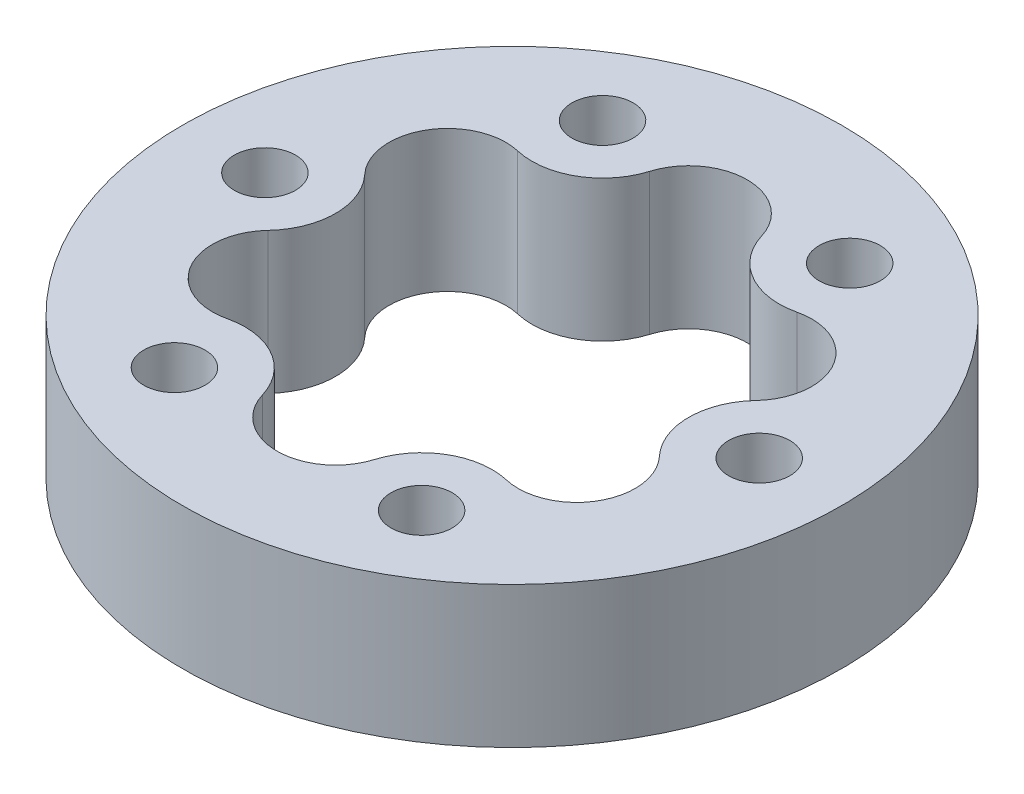
from build123d import *

# Parameters (mm, degrees)
SKETCH_1_R               = 28
SKETCH_1_R_2             = 2.6
EXTRUDE_1_DEPTH          = 12
CUT_EXTRUDE_2_DEPTH      = 1
CUT_EXTRUDE_2_DEPTH_BACK = 13


with BuildPart() as part:
    # 草图1 → 凸台-拉伸1 (new body)
    with BuildSketch(Plane(origin=(0, 0, 0), x_dir=(1, 0, 0), z_dir=(0, 1, 0))):
        Circle(SKETCH_1_R)
        with Locations((10.5, 18.186533479)):
            Circle(SKETCH_1_R_2, mode=Mode.SUBTRACT)
        with Locations((21, 0)):
            Circle(SKETCH_1_R_2, mode=Mode.SUBTRACT)
        with Locations((10.5, -18.186533479)):
            Circle(SKETCH_1_R_2, mode=Mode.SUBTRACT)
        with Locations((-10.5, -18.186533479)):
            Circle(SKETCH_1_R_2, mode=Mode.SUBTRACT)
        with Locations((-21, 0)):
            Circle(SKETCH_1_R_2, mode=Mode.SUBTRACT)
        with Locations((-10.5, 18.186533479)):
            Circle(SKETCH_1_R_2, mode=Mode.SUBTRACT)
    extrude(amount=EXTRUDE_1_DEPTH)

    # 草图4 → 切除-拉伸2 (cut, two sides)
    with BuildSketch(Plane(origin=(0, 12, 0), x_dir=(1, 0, 0), z_dir=(0, 1, 0))) as cut_extrude_2_sk:
        with BuildLine():
            ThreePointArc((4.758569662, 16.444127766), (7.500000636, 12.99038069), (11.861748987, 12.343106429))
            ThreePointArc((11.861748987, 12.343106429), (17.297017892, 9.986437089), (16.620317219, 4.10102167))
            ThreePointArc((16.620317219, 4.10102167), (15, -7.34e-07), (16.620318223, -4.101022742))
            ThreePointArc((16.620318223, -4.101022742), (17.297017158, -9.98643836), (11.861747557, -12.343106096))
            ThreePointArc((11.861747557, -12.343106096), (7.499999364, -12.990381424), (4.758569235, -16.444129171))
            ThreePointArc((4.758569235, -16.444129171), (-7.34e-07, -19.972875449), (-4.758569662, -16.444127766))
            ThreePointArc((-4.758569662, -16.444127766), (-7.500000636, -12.99038069), (-11.861748987, -12.343106429))
            ThreePointArc((-11.861748987, -12.343106429), (-17.297017892, -9.986437089), (-16.620317219, -4.10102167))
            ThreePointArc((-16.620317219, -4.10102167), (-15, 7.34e-07), (-16.620318223, 4.101022742))
            ThreePointArc((-16.620318223, 4.101022742), (-17.297017158, 9.98643836), (-11.861747557, 12.343106096))
            ThreePointArc((-11.861747557, 12.343106096), (-7.499999364, 12.990381424), (-4.758569235, 16.444129171))
            ThreePointArc((-4.758569235, 16.444129171), (7.34e-07, 19.972875449), (4.758569662, 16.444127766))
        make_face()
    extrude(amount=CUT_EXTRUDE_2_DEPTH, mode=Mode.SUBTRACT)
    extrude(cut_extrude_2_sk.sketch, amount=-CUT_EXTRUDE_2_DEPTH_BACK, mode=Mode.SUBTRACT)


solid = part.part
